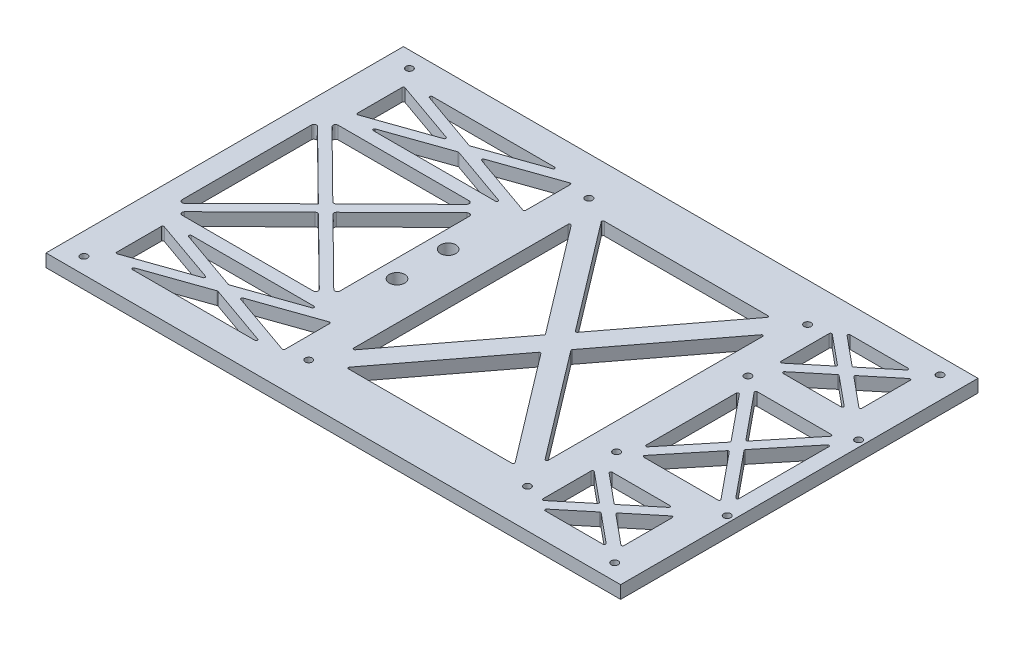
from build123d import *

# Parameters (mm, degrees)
SKETCH4_W                        = 224.59
SKETCH4_H                        = 139.7
TOPCHASSISBASE_DEPTH             = 5
BATTERYPACKMOUNTINGHOLESSKETCH_R = 1.375
BATTERYPACKMOUNTINGHOLES_DEPTH   = 7.5
F_9VBATTERYMOUNTINGHOLESSKETCH_R = 1.375
F_9VBATTERYMOUNTINGHOLES_DEPTH   = 7.5
DUALSWITCHMOUNTINGHOLESSKETCH_R  = 3
DUALSWITCHMOUNTINGHOLES_DEPTH    = 7.5
SKETCH5_R                        = 1.375
BOTTOMCHASSISMOUNTINGHOLES_DEPTH = 6
WEIGHTREDUCTION_DEPTH            = 6


with BuildPart() as part:
    # Sketch4 → topChassisBase (new body)
    with BuildSketch(Plane(origin=(0, 0, 0), x_dir=(1, 0, 0), z_dir=(0, 1, 0))):
        with Locations((27.955, 58)):
            Rectangle(SKETCH4_W, SKETCH4_H)
    extrude(amount=TOPCHASSISBASE_DEPTH)

    # batteryPackMountingHolesSketch → batteryPackMountingHoles (cut)
    with BuildSketch(Plane(origin=(0, 0, 0), x_dir=(1, 0, 0), z_dir=(0, 1, 0))):
        with Locations((3.25, 112.75)):
            Circle(BATTERYPACKMOUNTINGHOLESSKETCH_R)
        with Locations((3.25, 3.25)):
            Circle(BATTERYPACKMOUNTINGHOLESSKETCH_R)
        with Locations((88.75, 112.75)):
            Circle(BATTERYPACKMOUNTINGHOLESSKETCH_R)
        with Locations((88.75, 3.25)):
            Circle(BATTERYPACKMOUNTINGHOLESSKETCH_R)
    extrude(amount=BATTERYPACKMOUNTINGHOLES_DEPTH, mode=Mode.SUBTRACT)

    # 9VbatteryMountingHolesSketch → 9VbatteryMountingHoles (cut)
    with BuildSketch(Plane(origin=(0, 0, 0), x_dir=(1, 0, 0), z_dir=(0, 1, 0))):
        with Locations((94.5, 83.675)):
            Circle(F_9VBATTERYMOUNTINGHOLESSKETCH_R)
        with Locations((137.75, 83.675)):
            Circle(F_9VBATTERYMOUNTINGHOLESSKETCH_R)
        with Locations((94.5, 32.325)):
            Circle(F_9VBATTERYMOUNTINGHOLESSKETCH_R)
        with Locations((137.75, 32.325)):
            Circle(F_9VBATTERYMOUNTINGHOLESSKETCH_R)
    extrude(amount=F_9VBATTERYMOUNTINGHOLES_DEPTH, mode=Mode.SUBTRACT)

    # dualSwitchMountingHolesSketch → dualSwitchMountingHoles (cut)
    with BuildSketch(Plane(origin=(0, 0, 0), x_dir=(1, 0, 0), z_dir=(0, 1, 0))):
        with Locations((-7, 68)):
            Circle(DUALSWITCHMOUNTINGHOLESSKETCH_R)
        with Locations((-7, 48)):
            Circle(DUALSWITCHMOUNTINGHOLESSKETCH_R)
    extrude(amount=DUALSWITCHMOUNTINGHOLES_DEPTH, mode=Mode.SUBTRACT)

    # Sketch5 → bottomChassisMountingHoles (cut, through all)
    with BuildSketch(Plane(origin=(0, 5, 0), x_dir=(1, 0, 0), z_dir=(0, 1, 0))):
        with Locations((-75.7725, 121.6)):
            Circle(SKETCH5_R)
        with Locations((131.6825, 121.6)):
            Circle(SKETCH5_R)
        with Locations((-75.7725, -5.6)):
            Circle(SKETCH5_R)
        with Locations((131.6825, -5.6)):
            Circle(SKETCH5_R)
    extrude(amount=-BOTTOMCHASSISMOUNTINGHOLES_DEPTH, mode=Mode.SUBTRACT)

    # Sketch7 → weightReduction (cut, through all)
    with BuildSketch(Plane(origin=(0, 5, 0), x_dir=(1, 0, 0), z_dir=(0, 1, 0))):
        with BuildLine():
            Line((8.898081097, 100.207653938), (40.745966449, 58.302541634))
            ThreePointArc((40.745966449, 58.302541634), (40.847885351, 58), (40.745966449, 57.697458366))
            Line((40.745966449, 57.697458366), (8.898081097, 15.792346062))
            ThreePointArc((8.898081097, 15.792346062), (8.3403763, 15.621051992), (8, 16.094887695))
            Line((8, 16.094887695), (8, 99.905112305))
            ThreePointArc((8, 99.905112305), (8.3403763, 100.378948008), (8.898081097, 100.207653938))
        make_face()
        with BuildLine():
            Line((13.634033551, 8.802541634), (45.601918903, 50.865548675))
            ThreePointArc((45.601918903, 50.865548675), (46, 51.063007041), (46.398081097, 50.865548675))
            Line((46.398081097, 50.865548675), (78.365966449, 8.802541634))
            ThreePointArc((78.365966449, 8.802541634), (78.415808792, 8.277818562), (77.967885351, 8))
            Line((77.967885351, 8), (14.032114649, 8))
            ThreePointArc((14.032114649, 8), (13.584191208, 8.277818562), (13.634033551, 8.802541634))
        make_face()
        with BuildLine():
            Line((13.634033551, 107.197458366), (45.601918903, 65.134451325))
            ThreePointArc((45.601918903, 65.134451325), (46, 64.936992959), (46.398081097, 65.134451325))
            Line((46.398081097, 65.134451325), (78.365966449, 107.197458366))
            ThreePointArc((78.365966449, 107.197458366), (78.415808792, 107.722181438), (77.967885351, 108))
            Line((77.967885351, 108), (14.032114649, 108))
            ThreePointArc((14.032114649, 108), (13.584191208, 107.722181438), (13.634033551, 107.197458366))
        make_face()
        with BuildLine():
            Line((51.254033551, 57.697458366), (83.101918903, 15.792346062))
            ThreePointArc((83.101918903, 15.792346062), (83.6596237, 15.621051992), (84, 16.094887695))
            Line((84, 16.094887695), (84, 99.905112305))
            ThreePointArc((84, 99.905112305), (83.6596237, 100.378948008), (83.101918903, 100.207653938))
            Line((83.101918903, 100.207653938), (51.254033551, 58.302541634))
            ThreePointArc((51.254033551, 58.302541634), (51.152114649, 58), (51.254033551, 57.697458366))
        make_face()
        with BuildLine():
            Line((101.637535684, 80.175), (130.612464316, 80.175))
            ThreePointArc((130.612464316, 80.175), (131.064246542, 79.889226096), (130.999598487, 79.358571281))
            Line((130.999598487, 79.358571281), (116.51213417, 61.633908042))
            ThreePointArc((116.51213417, 61.633908042), (116.125, 61.450336761), (115.73786583, 61.633908042))
            Line((115.73786583, 61.633908042), (101.250401513, 79.358571281))
            ThreePointArc((101.250401513, 79.358571281), (101.185753458, 79.889226096), (101.637535684, 80.175))
        make_face()
        with BuildLine():
            Line((134.25, 75.612939101), (134.25, 40.387060899))
            ThreePointArc((134.25, 40.387060899), (133.91797755, 39.916121898), (133.36286583, 40.07063218))
            Line((133.36286583, 40.07063218), (118.966720566, 57.683571281))
            ThreePointArc((118.966720566, 57.683571281), (118.853854737, 58), (118.966720566, 58.316428719))
            Line((118.966720566, 58.316428719), (133.36286583, 75.92936782))
            ThreePointArc((133.36286583, 75.92936782), (133.91797755, 76.083878102), (134.25, 75.612939101))
        make_face()
        with BuildLine():
            Line((101.637535684, 35.825), (130.612464316, 35.825))
            ThreePointArc((130.612464316, 35.825), (131.064246542, 36.110773904), (130.999598487, 36.641428719))
            Line((130.999598487, 36.641428719), (116.51213417, 54.366091958))
            ThreePointArc((116.51213417, 54.366091958), (116.125, 54.549663239), (115.73786583, 54.366091958))
            Line((115.73786583, 54.366091958), (101.250401513, 36.641428719))
            ThreePointArc((101.250401513, 36.641428719), (101.185753458, 36.110773904), (101.637535684, 35.825))
        make_face()
        with BuildLine():
            Line((98, 75.612939101), (98, 40.387060899))
            ThreePointArc((98, 40.387060899), (98.33202245, 39.916121898), (98.88713417, 40.07063218))
            Line((98.88713417, 40.07063218), (113.283279434, 57.683571281))
            ThreePointArc((113.283279434, 57.683571281), (113.396145263, 58), (113.283279434, 58.316428719))
            Line((113.283279434, 58.316428719), (98.88713417, 75.92936782))
            ThreePointArc((98.88713417, 75.92936782), (98.33202245, 76.083878102), (98, 75.612939101))
        make_face()
        with BuildLine():
            Line((123.152140151, 117.6), (100.530359849, 117.6))
            ThreePointArc((100.530359849, 117.6), (100.05986385, 117.269214405), (100.211901047, 116.714534059))
            Line((100.211901047, 116.714534059), (111.522791198, 107.36986272))
            ThreePointArc((111.522791198, 107.36986272), (111.84125, 107.255328661), (112.159708802, 107.36986272))
            Line((112.159708802, 107.36986272), (123.470598953, 116.714534059))
            ThreePointArc((123.470598953, 116.714534059), (123.62263615, 117.269214405), (123.152140151, 117.6))
        make_face()
        with BuildLine():
            Line((96, 113.944088407), (96, 95.080911593))
            ThreePointArc((96, 95.080911593), (96.286961742, 94.628568028), (96.818458802, 94.695445652))
            Line((96.818458802, 94.695445652), (108.234554302, 104.127034059))
            ThreePointArc((108.234554302, 104.127034059), (108.4160955, 104.5125), (108.234554302, 104.897965941))
            Line((108.234554302, 104.897965941), (96.818458802, 114.329554348))
            ThreePointArc((96.818458802, 114.329554348), (96.286961742, 114.396431972), (96, 113.944088407))
        make_face()
        with BuildLine():
            Line((123.152140151, 91.425), (100.530359849, 91.425))
            ThreePointArc((100.530359849, 91.425), (100.05986385, 91.755785595), (100.211901047, 92.310465941))
            Line((100.211901047, 92.310465941), (111.522791198, 101.65513728))
            ThreePointArc((111.522791198, 101.65513728), (111.84125, 101.769671339), (112.159708802, 101.65513728))
            Line((112.159708802, 101.65513728), (123.470598953, 92.310465941))
            ThreePointArc((123.470598953, 92.310465941), (123.62263615, 91.755785595), (123.152140151, 91.425))
        make_face()
        with BuildLine():
            Line((127.6825, 113.944088407), (127.6825, 95.080911593))
            ThreePointArc((127.6825, 95.080911593), (127.395538258, 94.628568028), (126.864041198, 94.695445652))
            Line((126.864041198, 94.695445652), (115.447945698, 104.127034059))
            ThreePointArc((115.447945698, 104.127034059), (115.2664045, 104.5125), (115.447945698, 104.897965941))
            Line((115.447945698, 104.897965941), (126.864041198, 114.329554348))
            ThreePointArc((126.864041198, 114.329554348), (127.395538258, 114.396431972), (127.6825, 113.944088407))
        make_face()
        with BuildLine():
            Line((115.447945698, 11.102034059), (126.864041198, 1.670445652))
            ThreePointArc((126.864041198, 1.670445652), (127.395538258, 1.603568028), (127.6825, 2.055911593))
            Line((127.6825, 2.055911593), (127.6825, 20.919088407))
            ThreePointArc((127.6825, 20.919088407), (127.395538258, 21.371431972), (126.864041198, 21.304554348))
            Line((126.864041198, 21.304554348), (115.447945698, 11.872965941))
            ThreePointArc((115.447945698, 11.872965941), (115.2664045, 11.4875), (115.447945698, 11.102034059))
        make_face()
        with BuildLine():
            Line((100.211901047, 23.689534059), (111.522791198, 14.34486272))
            ThreePointArc((111.522791198, 14.34486272), (111.84125, 14.230328661), (112.159708802, 14.34486272))
            Line((112.159708802, 14.34486272), (123.470598953, 23.689534059))
            ThreePointArc((123.470598953, 23.689534059), (123.62263615, 24.244214405), (123.152140151, 24.575))
            Line((123.152140151, 24.575), (100.530359849, 24.575))
            ThreePointArc((100.530359849, 24.575), (100.05986385, 24.244214405), (100.211901047, 23.689534059))
        make_face()
        with BuildLine():
            Line((96.818458802, 1.670445652), (108.234554302, 11.102034059))
            ThreePointArc((108.234554302, 11.102034059), (108.4160955, 11.4875), (108.234554302, 11.872965941))
            Line((108.234554302, 11.872965941), (96.818458802, 21.304554348))
            ThreePointArc((96.818458802, 21.304554348), (96.286961742, 21.371431972), (96, 20.919088407))
            Line((96, 20.919088407), (96, 2.055911593))
            ThreePointArc((96, 2.055911593), (96.286961742, 1.603568028), (96.818458802, 1.670445652))
        make_face()
        with BuildLine():
            Line((123.152140151, -1.6), (100.530359849, -1.6))
            ThreePointArc((100.530359849, -1.6), (100.05986385, -1.269214405), (100.211901047, -0.714534059))
            Line((100.211901047, -0.714534059), (111.522791198, 8.63013728))
            ThreePointArc((111.522791198, 8.63013728), (111.84125, 8.744671339), (112.159708802, 8.63013728))
            Line((112.159708802, 8.63013728), (123.470598953, -0.714534059))
            ThreePointArc((123.470598953, -0.714534059), (123.62263615, -1.269214405), (123.152140151, -1.6))
        make_face()
        with BuildLine():
            Line((-5, 2.225309174), (-5, 19.674690826))
            ThreePointArc((-5, 19.674690826), (-5.210899627, 20.082638095), (-5.665683898, 20.146441656))
            Line((-5.665683898, 20.146441656), (-30.507446986, 11.42175083))
            ThreePointArc((-30.507446986, 11.42175083), (-30.841763088, 10.95), (-30.507446986, 10.47824917))
            Line((-30.507446986, 10.47824917), (-5.665683898, 1.753558344))
            ThreePointArc((-5.665683898, 1.753558344), (-5.210899627, 1.817361905), (-5, 2.225309174))
        make_face()
        with BuildLine():
            Line((-61.804365902, 22.5), (-13.968134098, 22.5))
            ThreePointArc((-13.968134098, 22.5), (-13.475246984, 22.084037446), (-13.8024502, 21.52824917))
            Line((-13.8024502, 21.52824917), (-37.720566102, 13.127953038))
            ThreePointArc((-37.720566102, 13.127953038), (-37.88625, 13.099703868), (-38.051933898, 13.127953038))
            Line((-38.051933898, 13.127953038), (-61.9700498, 21.52824917))
            ThreePointArc((-61.9700498, 21.52824917), (-62.297253016, 22.084037446), (-61.804365902, 22.5))
        make_face()
        with BuildLine():
            Line((-70.7725, 2.225309174), (-70.7725, 19.674690826))
            ThreePointArc((-70.7725, 19.674690826), (-70.561600373, 20.082638095), (-70.106816102, 20.146441656))
            Line((-70.106816102, 20.146441656), (-45.265053014, 11.42175083))
            ThreePointArc((-45.265053014, 11.42175083), (-44.930736912, 10.95), (-45.265053014, 10.47824917))
            Line((-45.265053014, 10.47824917), (-70.106816102, 1.753558344))
            ThreePointArc((-70.106816102, 1.753558344), (-70.561600373, 1.817361905), (-70.7725, 2.225309174))
        make_face()
        with BuildLine():
            Line((-61.804365902, -0.6), (-13.968134098, -0.6))
            ThreePointArc((-13.968134098, -0.6), (-13.475246984, -0.184037446), (-13.8024502, 0.37175083))
            Line((-13.8024502, 0.37175083), (-37.720566102, 8.772046962))
            ThreePointArc((-37.720566102, 8.772046962), (-37.88625, 8.800296132), (-38.051933898, 8.772046962))
            Line((-38.051933898, 8.772046962), (-61.9700498, 0.37175083))
            ThreePointArc((-61.9700498, 0.37175083), (-62.297253016, -0.184037446), (-61.804365902, -0.6))
        make_face()
        with BuildLine():
            Line((-61.9700498, 115.62824917), (-38.051933898, 107.227953038))
            ThreePointArc((-38.051933898, 107.227953038), (-37.88625, 107.199703868), (-37.720566102, 107.227953038))
            Line((-37.720566102, 107.227953038), (-13.8024502, 115.62824917))
            ThreePointArc((-13.8024502, 115.62824917), (-13.475246984, 116.184037446), (-13.968134098, 116.6))
            Line((-13.968134098, 116.6), (-61.804365902, 116.6))
            ThreePointArc((-61.804365902, 116.6), (-62.297253016, 116.184037446), (-61.9700498, 115.62824917))
        make_face()
        with BuildLine():
            Line((-30.507446986, 104.57824917), (-5.665683898, 95.853558344))
            ThreePointArc((-5.665683898, 95.853558344), (-5.210899627, 95.917361905), (-5, 96.325309174))
            Line((-5, 96.325309174), (-5, 113.774690826))
            ThreePointArc((-5, 113.774690826), (-5.210899627, 114.182638095), (-5.665683898, 114.246441656))
            Line((-5.665683898, 114.246441656), (-30.507446986, 105.52175083))
            ThreePointArc((-30.507446986, 105.52175083), (-30.841763088, 105.05), (-30.507446986, 104.57824917))
        make_face()
        with BuildLine():
            Line((-61.9700498, 94.47175083), (-38.051933898, 102.872046962))
            ThreePointArc((-38.051933898, 102.872046962), (-37.88625, 102.900296132), (-37.720566102, 102.872046962))
            Line((-37.720566102, 102.872046962), (-13.8024502, 94.47175083))
            ThreePointArc((-13.8024502, 94.47175083), (-13.475246984, 93.915962554), (-13.968134098, 93.5))
            Line((-13.968134098, 93.5), (-61.804365902, 93.5))
            ThreePointArc((-61.804365902, 93.5), (-62.297253016, 93.915962554), (-61.9700498, 94.47175083))
        make_face()
        with BuildLine():
            Line((-70.106816102, 114.246441656), (-45.265053014, 105.52175083))
            ThreePointArc((-45.265053014, 105.52175083), (-44.930736912, 105.05), (-45.265053014, 104.57824917))
            Line((-45.265053014, 104.57824917), (-70.106816102, 95.853558344))
            ThreePointArc((-70.106816102, 95.853558344), (-70.561600373, 95.917361905), (-70.7725, 96.325309174))
            Line((-70.7725, 96.325309174), (-70.7725, 113.774690826))
            ThreePointArc((-70.7725, 113.774690826), (-70.561600373, 114.182638095), (-70.106816102, 114.246441656))
        make_face()
        with BuildLine():
            Line((-18.579609732, 86.788458099), (-44.183606333, 61.504653936))
            ThreePointArc((-44.183606333, 61.504653936), (-44.88625, 61.216195837), (-45.588893667, 61.504653936))
            Line((-45.588893667, 61.504653936), (-71.192890268, 86.788458099))
            ThreePointArc((-71.192890268, 86.788458099), (-71.41532549, 87.879774999), (-70.490246601, 88.5))
            Line((-70.490246601, 88.5), (-19.282253399, 88.5))
            ThreePointArc((-19.282253399, 88.5), (-18.35717451, 87.879774999), (-18.579609732, 86.788458099))
        make_face()
        with BuildLine():
            Line((-74.069856333, 84.007851629), (-47.732642976, 58))
            Line((-47.732642976, 58), (-74.069856333, 31.992148371))
            ThreePointArc((-74.069856333, 31.992148371), (-75.158088078, 31.78101924), (-75.7725, 32.703690272))
            Line((-75.7725, 32.703690272), (-75.7725, 83.296309728))
            ThreePointArc((-75.7725, 83.296309728), (-75.158088078, 84.21898076), (-74.069856333, 84.007851629))
        make_face()
        with BuildLine():
            Line((-15.702643667, 84.007851629), (-41.319304203, 58.711541901))
            ThreePointArc((-41.319304203, 58.711541901), (-41.616660535, 58), (-41.319304203, 57.288458099))
            Line((-41.319304203, 57.288458099), (-15.702643667, 31.992148371))
            ThreePointArc((-15.702643667, 31.992148371), (-14.614411922, 31.78101924), (-14, 32.703690272))
            Line((-14, 32.703690272), (-14, 83.296309728))
            ThreePointArc((-14, 83.296309728), (-14.614411922, 84.21898076), (-15.702643667, 84.007851629))
        make_face()
        with BuildLine():
            Line((-70.490246601, 27.5), (-19.282253399, 27.5))
            ThreePointArc((-19.282253399, 27.5), (-18.35717451, 28.120225001), (-18.579609732, 29.211541901))
            Line((-18.579609732, 29.211541901), (-44.183606333, 54.495346064))
            ThreePointArc((-44.183606333, 54.495346064), (-44.88625, 54.783804163), (-45.588893667, 54.495346064))
            Line((-45.588893667, 54.495346064), (-71.192890268, 29.211541901))
            ThreePointArc((-71.192890268, 29.211541901), (-71.41532549, 28.120225001), (-70.490246601, 27.5))
        make_face()
    extrude(amount=-WEIGHTREDUCTION_DEPTH, mode=Mode.SUBTRACT)


solid = part.part
